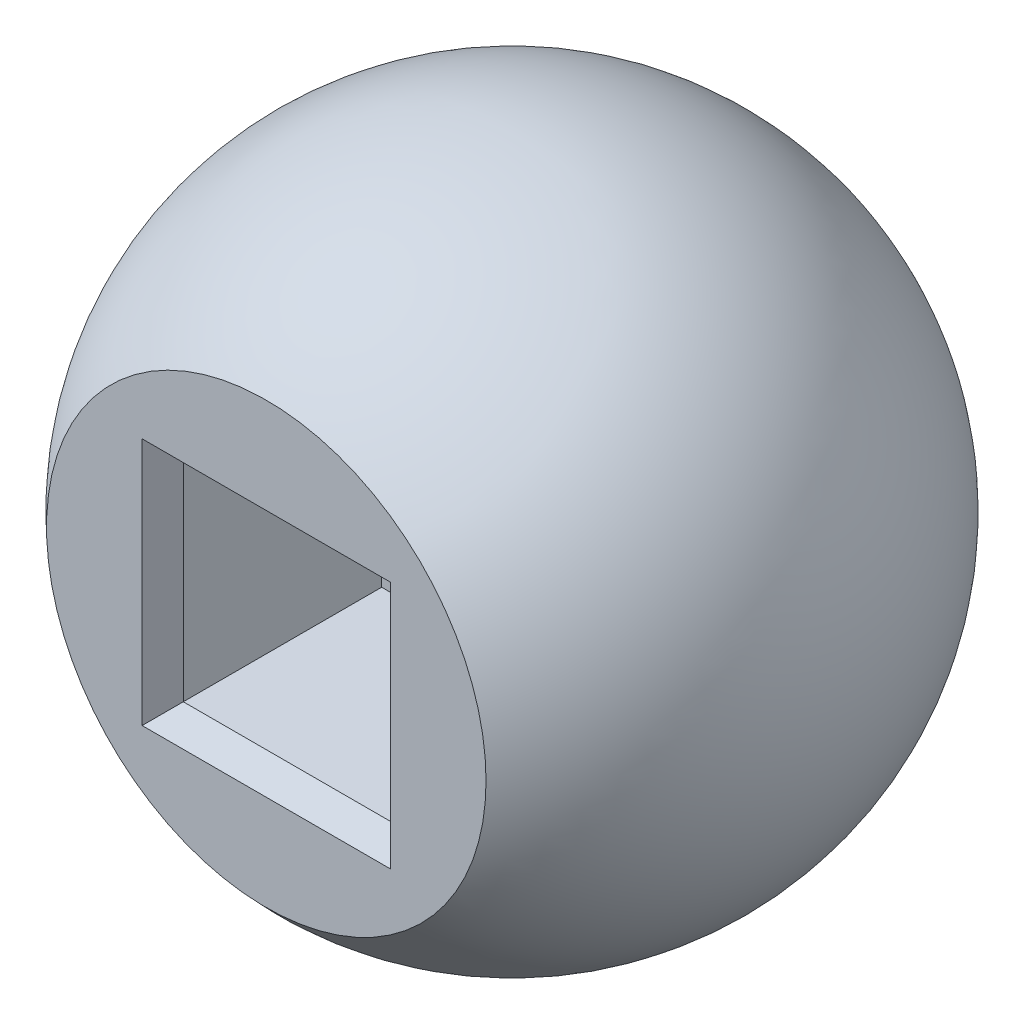
from build123d import *

# Parameters (mm, degrees)
SKETCH3_W          = 10.3
SKETCH3_H          = 10.3
CUT_EXTRUDE1_DEPTH = 10.4
SKETCH4_R          = 2.15
CUT_EXTRUDE2_DEPTH = 16.780339887
CUT_EXTRUDE3_START = -10
SKETCH5_R          = 4.5
CUT_EXTRUDE3_DEPTH = 6.62545693
CHAMFER1_SIZE      = 0.5
CHAMFER1_SIZE2     = 1.37373871


with BuildPart() as part:
    # Sketch2 → Revolve1 (revolve)
    with BuildSketch(Plane(origin=(0, 0, 0), x_dir=(1, 0, 0), z_dir=(0, 1, 0))):
        with BuildLine():
            Line((0, 15), (0, -11.180339887))
            Line((0, -11.180339887), (10, -11.180339887))
            ThreePointArc((10, -11.180339887), (14.012585384, 5.352331347), (0, 15))
        make_face()
    revolve(axis=Axis((0, 0, 15), (0, 0, -1)))

    # Sketch3 → Cut-Extrude1 (cut)
    with BuildSketch(Plane.XY.offset(11.180339887)):
        Rectangle(SKETCH3_W, SKETCH3_H)
    extrude(amount=-CUT_EXTRUDE1_DEPTH, mode=Mode.SUBTRACT)

    # Sketch4 → Cut-Extrude2 (cut, through all)
    with BuildSketch(Plane.XY.offset(0.780339887)):
        Circle(SKETCH4_R)
    extrude(amount=-CUT_EXTRUDE2_DEPTH, mode=Mode.SUBTRACT)

    # Sketch5 → Cut-Extrude3 (cut, through all)
    with BuildSketch(Plane.XY.offset(0.780339887).offset(CUT_EXTRUDE3_START)):
        Circle(SKETCH5_R)
    extrude(amount=-CUT_EXTRUDE3_DEPTH, mode=Mode.SUBTRACT)

    # Chamfer1
    chamfer1_edges = [part.edges().sort_by_distance(p)[0] for p in [
        (5.15, 0, 11.180339887),
        (0, 5.15, 11.180339887),
        (-5.15, 0, 11.180339887),
        (0, -5.15, 11.180339887),
    ]]
    chamfer1_side = [part.faces().sort_by_distance(p)[0] for p in [
        (-9.717157288, 0, 11.180339887),
    ]]
    chamfer(chamfer1_edges, length=CHAMFER1_SIZE, length2=CHAMFER1_SIZE2, reference=chamfer1_side[0])


solid = part.part
